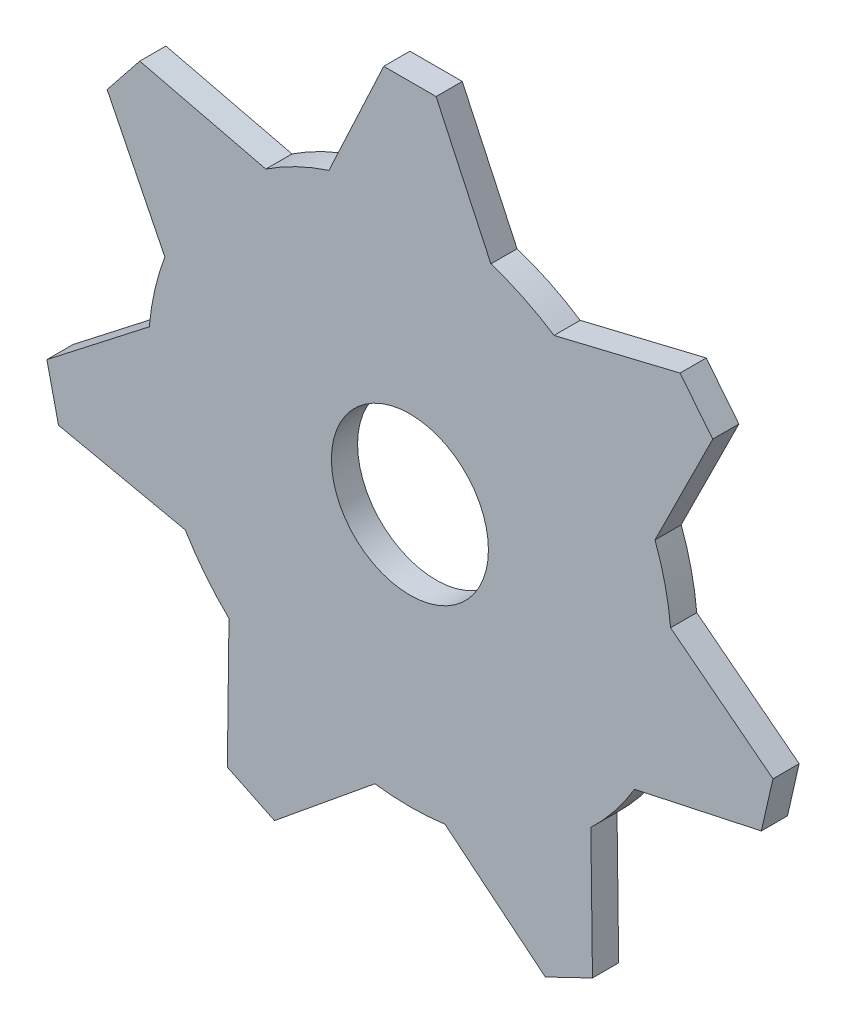
from build123d import *

# Parameters (mm, degrees)
SKETCH1_R           = 12.7
BOSS_EXTRUDE1_DEPTH = 1.27
BOSS_EXTRUDE2_DEPTH = 1.27
CIRPATTERN1_COUNT   = 7
SKETCH4_R           = 3.81
CUT_EXTRUDE1_DEPTH  = 1.27


with BuildPart() as part:
    # Sketch1 → Boss-Extrude1 (new body)
    with BuildSketch(Plane.XY):
        Circle(SKETCH1_R)
    extrude(amount=BOSS_EXTRUDE1_DEPTH)

    # Sketch3 → Boss-Extrude2 (add)
    with BuildSketch(Plane.XY.offset(1.27)):
        Polygon((0, 17.78), (-1.27, 17.78), (-3.929437707, 12.076817433), (3.929437707, 12.076817433), (1.27, 17.78), align=None)
    boss_extrude2 = extrude(amount=-BOSS_EXTRUDE2_DEPTH)

    # CirPattern1: Boss-Extrude2 ×7 about axis
    cirpattern1_axis = Axis((0, 0, 0), (0, 0, 1))
    for i in range(1, CIRPATTERN1_COUNT):
        add(boss_extrude2.rotate(cirpattern1_axis, i * 360 / CIRPATTERN1_COUNT))

    # Sketch4 → Cut-Extrude1 (cut)
    with BuildSketch(Plane(origin=(0, 0, 0), x_dir=(-1, 0, 0), z_dir=(0, 0, -1))):
        Circle(SKETCH4_R)
    extrude(amount=-CUT_EXTRUDE1_DEPTH, mode=Mode.SUBTRACT)


solid = part.part
